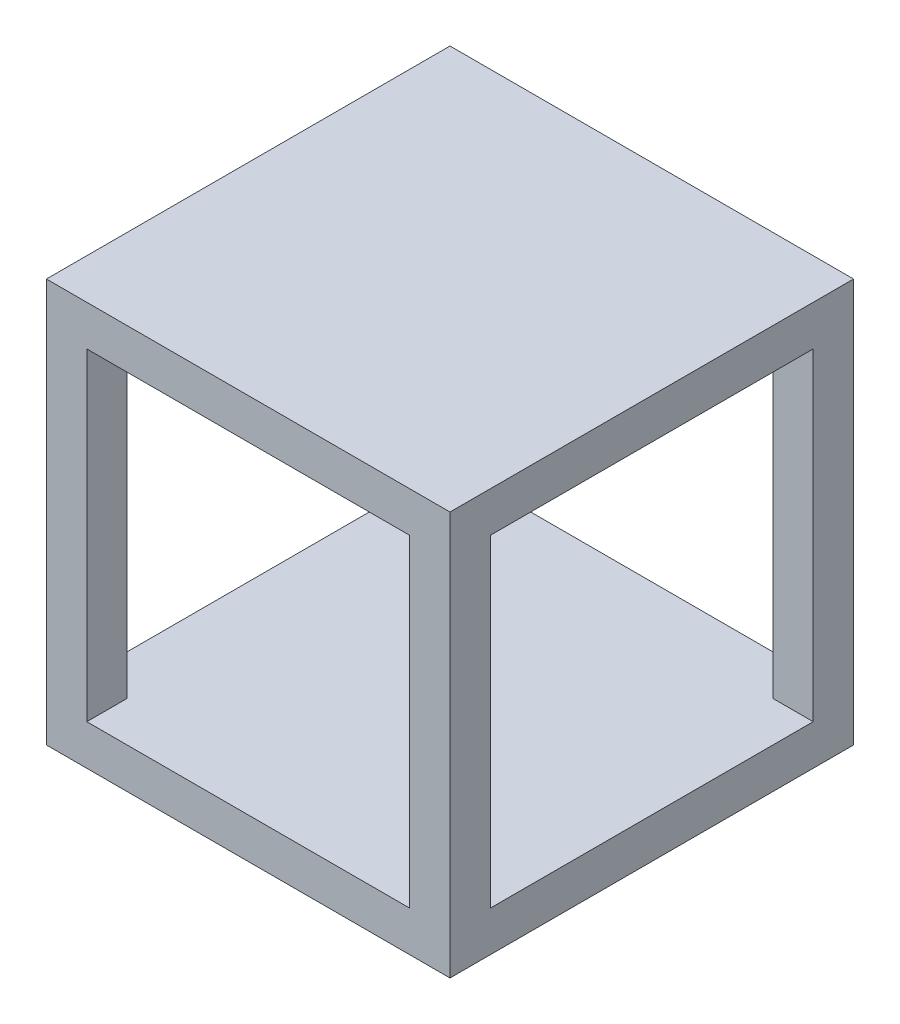
from build123d import *

# Parameters (mm, degrees)
SKETCH2_W           = 50
SKETCH2_H           = 50
BOSS_EXTRUDE1_DEPTH = 50
SKETCH4_W           = 40
SKETCH4_H           = 40
CUT_EXTRUDE1_DEPTH  = 50
SKETCH7_W           = 40
SKETCH7_H           = 40
CUT_EXTRUDE2_DEPTH  = 50
SKETCH10_W          = 45.5
SKETCH10_H          = 45.5
SKETCH10_W_2        = 41.063521317
SKETCH10_H_2        = 40.909775363
CUT_EXTRUDE3_DEPTH  = 2.5


with BuildPart() as part:
    # Sketch2 → Boss-Extrude1 (new body)
    with BuildSketch(Plane.XY):
        with Locations((25, 25)):
            Rectangle(SKETCH2_W, SKETCH2_H)
    extrude(amount=BOSS_EXTRUDE1_DEPTH)

    # Sketch4 → Cut-Extrude1 (cut)
    with BuildSketch(Plane.XY.offset(50)):
        with Locations((25, 25)):
            Rectangle(SKETCH4_W, SKETCH4_H)
    extrude(amount=-CUT_EXTRUDE1_DEPTH, mode=Mode.SUBTRACT)

    # Sketch7 → Cut-Extrude2 (cut)
    with BuildSketch(Plane(origin=(0, 0, 0), x_dir=(0, 0, -1), z_dir=(1, 0, 0))):
        with Locations((-25, 25)):
            Rectangle(SKETCH7_W, SKETCH7_H)
    extrude(amount=CUT_EXTRUDE2_DEPTH, mode=Mode.SUBTRACT)

    # Sketch10 → Cut-Extrude3 (cut)
    with BuildSketch(Plane(origin=(0, 0, 0), x_dir=(1, 0, 0), z_dir=(0, 1, 0))):
        with Locations((25, -25)):
            Rectangle(SKETCH10_W, SKETCH10_H)
        with Locations((25.031760659, -24.954887682)):
            Rectangle(SKETCH10_W_2, SKETCH10_H_2, mode=Mode.SUBTRACT)
    extrude(amount=CUT_EXTRUDE3_DEPTH, mode=Mode.SUBTRACT)


solid = part.part
